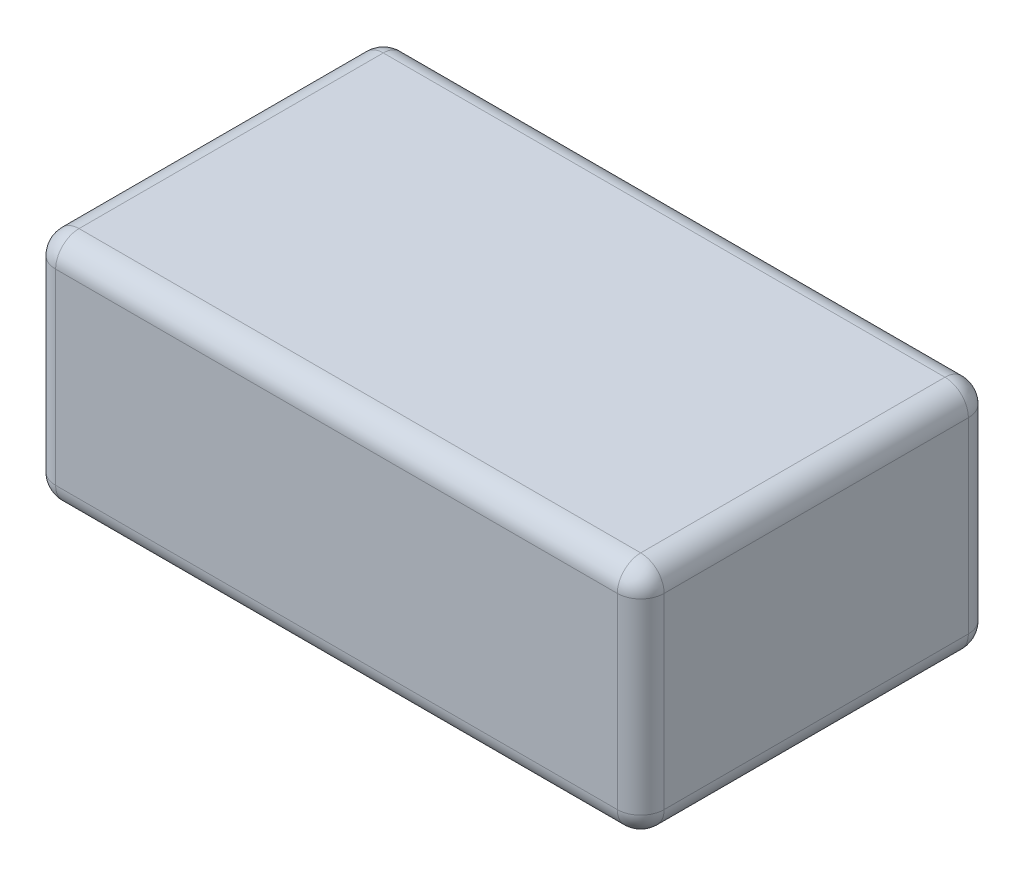
from build123d import *

# Parameters (mm, degrees)
SKETCH1_W           = 52
SKETCH1_H           = 30
BOSS_EXTRUDE1_DEPTH = 20
FILLET1_R           = 2


with BuildPart() as part:
    # Sketch1 → Boss-Extrude1 (new body)
    with BuildSketch(Plane(origin=(0, 0, 0), x_dir=(1, 0, 0), z_dir=(0, 1, 0))):
        Rectangle(SKETCH1_W, SKETCH1_H)
    extrude(amount=BOSS_EXTRUDE1_DEPTH)

    # Fillet1
    fillet1_edges = [part.edges().sort_by_distance(p)[0] for p in [
        (-26, 20, 0),
        (0, 20, 15),
        (26, 20, 0),
        (0, 0, 15),
        (-26, 0, 0),
        (0, 0, -15),
        (26, 0, 0),
        (0, 20, -15),
        (26, 10, 15),
        (-26, 10, 15),
        (-26, 10, -15),
        (26, 10, -15),
    ]]
    fillet(fillet1_edges, radius=FILLET1_R)


solid = part.part
